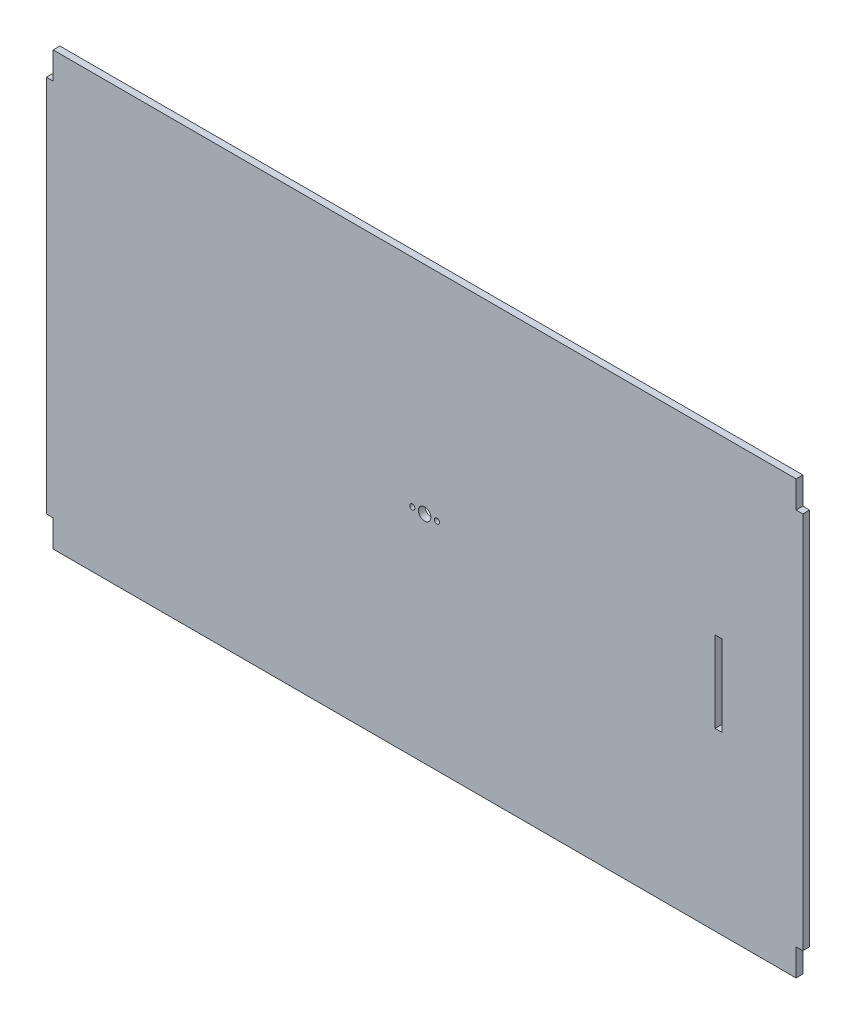
from build123d import *

# Parameters (mm, degrees)
SHELF_DEPTH              = 3.175
TILT_MOUNT_SLOT_SKETCH_W = 3.175
TILT_MOUNT_SLOT_SKETCH_H = 38.1
TILT_MOUNT_SLOT_DEPTH    = 4.175
SKETCH2_R                = 2.921
SKETCH2_R_2              = 1.2065
CUT_EXTRUDE1_DEPTH       = 4.175


with BuildPart() as part:
    # Sketch1 → Shelf (new body)
    with BuildSketch(Plane.XY):
        Polygon((3.175, 203.2), (3.175, 190.5), (0, 190.5), (0, 12.7), (3.175, 12.7), (3.175, 0), (352.425, 0), (352.425, 12.7), (355.6, 12.7), (355.6, 190.5), (352.425, 190.5), (352.425, 203.2), align=None)
    extrude(amount=SHELF_DEPTH)

    # Tilt mount slot sketch → Tilt Mount Slot (cut, through all)
    with BuildSketch(Plane.XY.offset(3.175)):
        with Locations((315.9125, 101.6)):
            Rectangle(TILT_MOUNT_SLOT_SKETCH_W, TILT_MOUNT_SLOT_SKETCH_H)
    extrude(amount=-TILT_MOUNT_SLOT_DEPTH, mode=Mode.SUBTRACT)

    # Sketch2 → Cut-Extrude1 (cut, through all)
    with BuildSketch(Plane.XY.offset(3.175)):
        with Locations((177.8, 101.6)):
            Circle(SKETCH2_R)
        with Locations((183.5785, 101.6)):
            Circle(SKETCH2_R_2)
        with Locations((172.0215, 101.6)):
            Circle(SKETCH2_R_2)
    extrude(amount=-CUT_EXTRUDE1_DEPTH, mode=Mode.SUBTRACT)


solid = part.part
